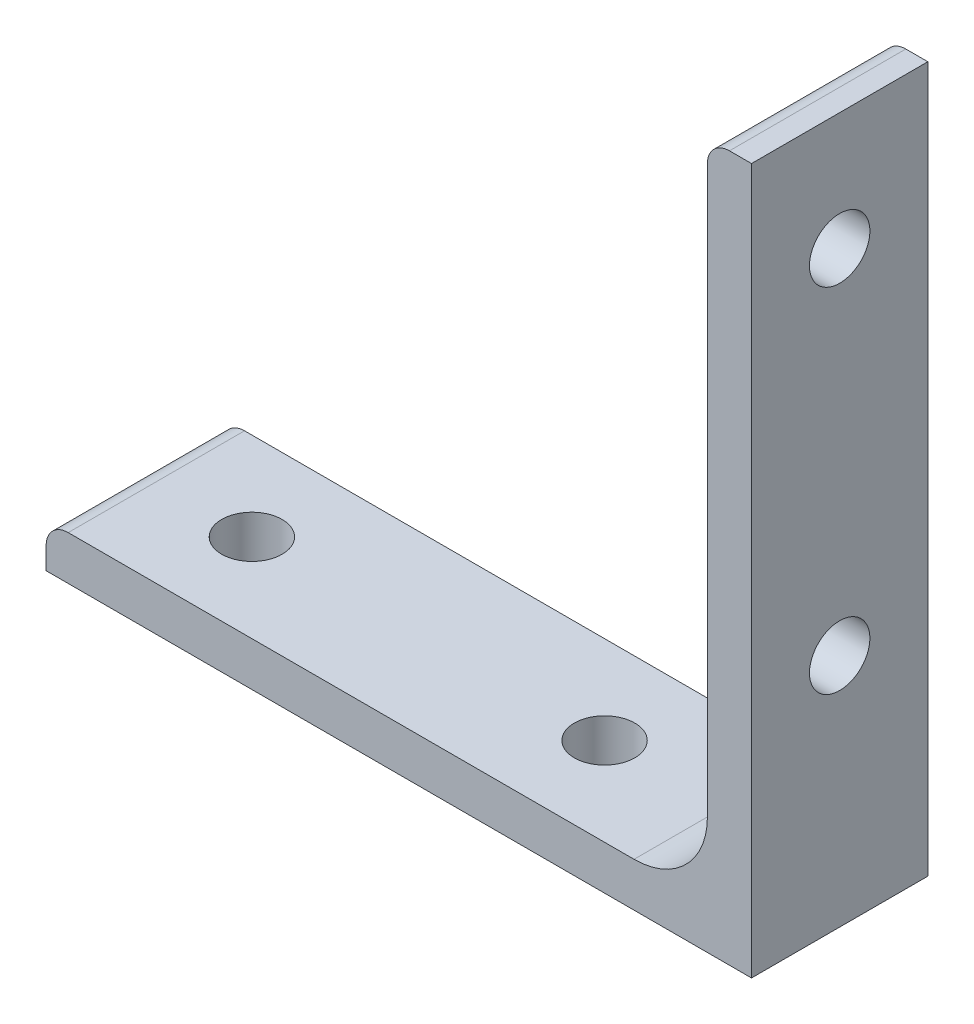
from build123d import *

# Parameters (mm, degrees)
BOSS_EXTRUDE1_DEPTH      = 9.525
F_0_257_DIAMETER_HOLE1_D = 6.5278


with BuildPart() as part:
    # Sketch2 → Boss-Extrude1 (new, symmetric)
    with BuildSketch(Plane.XY):
        with BuildLine():
            Line((-38.1, -38.1), (38.1, -38.1))
            Line((38.1, -38.1), (38.1, 38.1))
            Line((38.1, 38.1), (35.71875, 38.1))
            ThreePointArc((35.71875, 38.1), (34.034951977, 37.402548023), (33.3375, 35.71875))
            Line((33.3375, 35.71875), (33.3375, -25.4127))
            ThreePointArc((33.3375, -25.4127), (31.01637982, -31.01637982), (25.4127, -33.3375))
            Line((25.4127, -33.3375), (-35.71875, -33.3375))
            ThreePointArc((-35.71875, -33.3375), (-37.402548023, -34.034951977), (-38.1, -35.71875))
            Line((-38.1, -35.71875), (-38.1, -38.1))
        make_face()
    extrude(amount=BOSS_EXTRUDE1_DEPTH, both=True)

    # F (0.257) Diameter Hole1 (through all)
    with Locations(Plane(origin=(0, -33.3375, 0), x_dir=(1, 0, 0), z_dir=(0, 1, 0))):
        with Locations((12.7, 0), (-25.4, 0)):
            f_0_257_diameter_hole1 = Hole(F_0_257_DIAMETER_HOLE1_D / 2)

    # Mirror1: F (0.257) Diameter Hole1 across plane
    add(f_0_257_diameter_hole1.mirror(Plane(origin=(0, 0, 0), x_dir=(0, 0, 1), z_dir=(0.7071067811865474, 0.7071067811865478, 0))), mode=Mode.SUBTRACT)


solid = part.part
